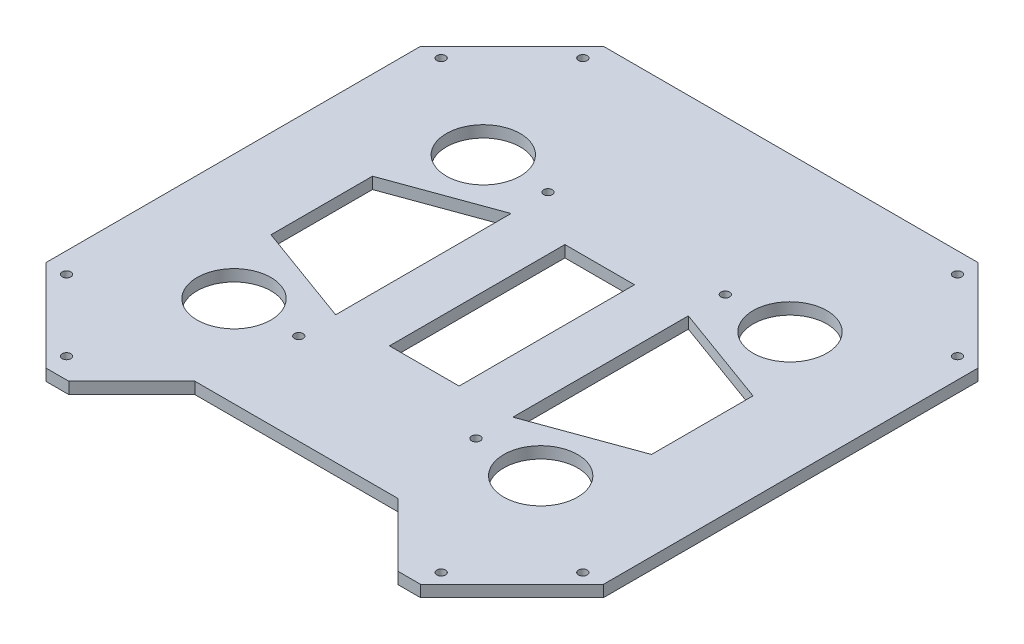
from build123d import *

# Parameters (mm, degrees)
SKETCH1_R           = 40.4
SKETCH1_R_2         = 4.7625
BOSS_EXTRUDE1_DEPTH = 12.7
CUT_EXTRUDE1_DEPTH  = 5000
SKETCH3_R           = 4.7625
CUT_EXTRUDE2_DEPTH  = 5000
CUT_EXTRUDE3_DEPTH  = 20
SKETCH5_W           = 38.1
SKETCH5_H           = 192.02128445
CUT_EXTRUDE4_DEPTH  = 78.232


with BuildPart() as part:
    # Sketch1 → Boss-Extrude1 (new body)
    with BuildSketch(Plane(origin=(0, 0, 0), x_dir=(1, 0, 0), z_dir=(0, 1, 0))):
        Polygon((205, 0), (305, 100), (305, 510), (205, 610), (-205, 610), (-305, 510), (-305, 100), (-205, 0), align=None)
        with Locations((-167.82128445, 168.589357775)):
            Circle(SKETCH1_R, mode=Mode.SUBTRACT)
        with Locations((-97, 168.589357775)):
            Circle(SKETCH1_R_2, mode=Mode.SUBTRACT)
        with Locations((97, 168.589357775)):
            Circle(SKETCH1_R_2, mode=Mode.SUBTRACT)
        with Locations((167.82128445, 168.589357775)):
            Circle(SKETCH1_R, mode=Mode.SUBTRACT)
        with Locations((-167.82128445, 441.410642225)):
            Circle(SKETCH1_R, mode=Mode.SUBTRACT)
        with Locations((-97, 441.410642225)):
            Circle(SKETCH1_R_2, mode=Mode.SUBTRACT)
        with Locations((97, 441.410642225)):
            Circle(SKETCH1_R_2, mode=Mode.SUBTRACT)
        with Locations((167.82128445, 441.410642225)):
            Circle(SKETCH1_R, mode=Mode.SUBTRACT)
    extrude(amount=BOSS_EXTRUDE1_DEPTH)

    # Sketch2 → Cut-Extrude1 (cut)
    with BuildSketch(Plane(origin=(0, 12.7, 0), x_dir=(1, 0, 0), z_dir=(0, 1, 0))):
        Polygon((-111, 69), (-180, 0), (180, 0), (111, 69), align=None)
    extrude(amount=-CUT_EXTRUDE1_DEPTH, mode=Mode.SUBTRACT)

    # Sketch3 → Cut-Extrude2 (cut)
    with BuildSketch(Plane(origin=(0, 12.7, 0), x_dir=(1, 0, 0), z_dir=(0, 1, 0))):
        with Locations((-205, 22.45771137)):
            Circle(SKETCH3_R)
        with Locations((205, 22.45771137)):
            Circle(SKETCH3_R)
        with Locations((-282.54228863, 100)):
            Circle(SKETCH3_R)
        with Locations((282.54228863, 100)):
            Circle(SKETCH3_R)
        with Locations((282.54228863, 510)):
            Circle(SKETCH3_R)
        with Locations((205, 587.54228863)):
            Circle(SKETCH3_R)
        with Locations((-205, 587.54228863)):
            Circle(SKETCH3_R)
        with Locations((-282.54228863, 510)):
            Circle(SKETCH3_R)
    extrude(amount=-CUT_EXTRUDE2_DEPTH, mode=Mode.SUBTRACT)

    # Sketch4 → Cut-Extrude3 (cut)
    with BuildSketch(Plane(origin=(0, 12.7, 0), x_dir=(1, 0, 0), z_dir=(0, 1, 0))):
        Polygon((-208.22128445, 360.529405268), (-97, 401.010642225), (-97, 208.989357775), (-208.22128445, 249.470594732), align=None)
        Polygon((208.22128445, 249.470594732), (208.22128445, 360.529405268), (97, 401.010642225), (97, 208.989357775), align=None)
    extrude(amount=-CUT_EXTRUDE3_DEPTH, mode=Mode.SUBTRACT)

    # Sketch5 → Cut-Extrude4 (cut)
    with BuildSketch(Plane(origin=(0, 12.7, 0), x_dir=(1, 0, 0), z_dir=(0, 1, 0))):
        with Locations((-19.05, 305)):
            Rectangle(SKETCH5_W, SKETCH5_H)
        with Locations((19.05, 305)):
            Rectangle(SKETCH5_W, SKETCH5_H)
    extrude(amount=-CUT_EXTRUDE4_DEPTH, mode=Mode.SUBTRACT)


solid = part.part
